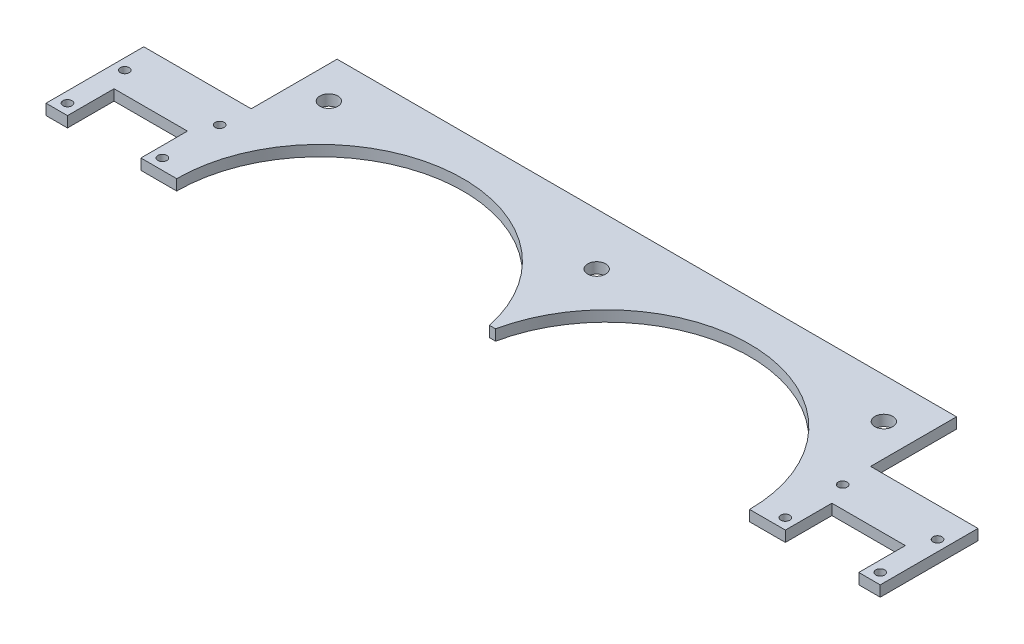
from build123d import *

# Parameters (mm, degrees)
ESQUISSE1_R      = 1.25
ESQUISSE1_R_2    = 2.5
EXTRUSION1_DEPTH = 3


with BuildPart() as part:
    # Esquisse1 → Extrusion1 (new body)
    with BuildSketch(Plane(origin=(0, 0, 0), x_dir=(1, 0, 0), z_dir=(0, 1, 0))):
        with BuildLine():
            Line((-119.250326512, 8.795182269), (-113.250326512, 8.795182269))
            Line((-113.250326512, 8.795182269), (-113.250326512, 21.795182269))
            Line((-113.250326512, 21.795182269), (-92.750326512, 21.795182269))
            Line((-92.750326512, 21.795182269), (-92.750326512, 8.795182269))
            Line((-92.750326512, 8.795182269), (-82.750326512, 8.795182269))
            ThreePointArc((-82.750326512, 8.795182269), (-46.875027378, 48.581949451), (-3.600984374, 17.000607921))
            Line((-3.600984374, 17.000607921), (-1.899668651, 17.000607921))
            ThreePointArc((-1.899668651, 17.000607921), (41.374374353, 48.581949451), (77.249673488, 8.795182269))
            Line((77.249673488, 8.795182269), (87.249673488, 8.795182269))
            Line((87.249673488, 8.795182269), (87.249673488, 21.795182269))
            Line((87.249673488, 21.795182269), (107.749673488, 21.795182269))
            Line((107.749673488, 21.795182269), (107.749673488, 8.795182269))
            Line((107.749673488, 8.795182269), (113.749673488, 8.795182269))
            Line((113.749673488, 8.795182269), (113.749673488, 36.099018287))
            Line((113.749673488, 36.099018287), (83.749673488, 36.099018287))
            Line((83.749673488, 36.099018287), (83.749673488, 60.099018287))
            Line((83.749673488, 60.099018287), (-89.250326512, 60.099018287))
            Line((-89.250326512, 60.099018287), (-89.250326512, 36.099018287))
            Line((-89.250326512, 36.099018287), (-119.250326512, 36.099018287))
            Line((-119.250326512, 36.099018287), (-119.250326512, 8.795182269))
        make_face()
        with Locations((110.749673488, 11.795182269)):
            Circle(ESQUISSE1_R, mode=Mode.SUBTRACT)
        with Locations((-2.250326512, 45.599018287)):
            Circle(ESQUISSE1_R_2, mode=Mode.SUBTRACT)
        with Locations((84.249673488, 27.795182269)):
            Circle(ESQUISSE1_R, mode=Mode.SUBTRACT)
        with Locations((110.749673488, 27.795182269)):
            Circle(ESQUISSE1_R, mode=Mode.SUBTRACT)
        with Locations((-80.250326512, 48.795182269)):
            Circle(ESQUISSE1_R_2, mode=Mode.SUBTRACT)
        with Locations((74.749673488, 48.795182269)):
            Circle(ESQUISSE1_R_2, mode=Mode.SUBTRACT)
        with Locations((-116.250326512, 27.795182269)):
            Circle(ESQUISSE1_R, mode=Mode.SUBTRACT)
        with Locations((-89.750326512, 27.795182269)):
            Circle(ESQUISSE1_R, mode=Mode.SUBTRACT)
        with Locations((-89.750326512, 11.795182269)):
            Circle(ESQUISSE1_R, mode=Mode.SUBTRACT)
        with Locations((84.249673488, 11.795182269)):
            Circle(ESQUISSE1_R, mode=Mode.SUBTRACT)
        with Locations((-116.250326512, 11.795182269)):
            Circle(ESQUISSE1_R, mode=Mode.SUBTRACT)
    extrude(amount=EXTRUSION1_DEPTH)


solid = part.part
